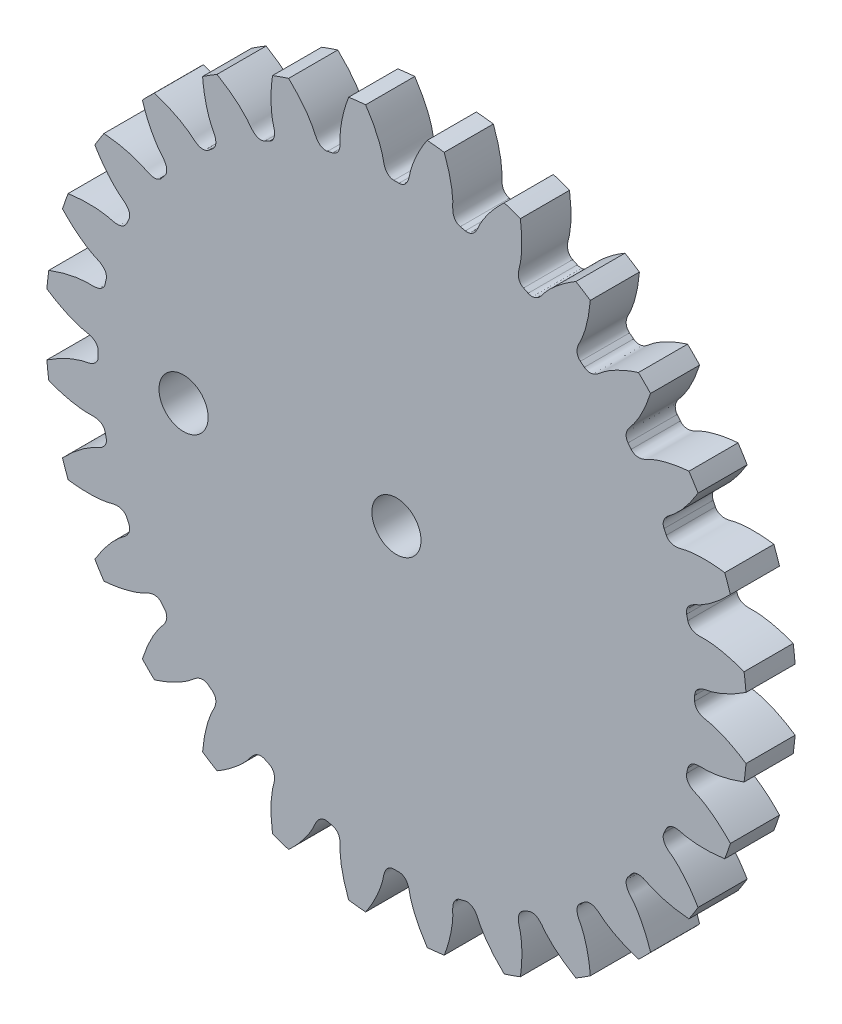
from build123d import *

# Parameters (mm, degrees)
GEAR_BASESKETCH_R                         = 21.428571429
COMPANY_STANDARD_1_40_0000MM_P_D_DEPTH    = 1.5
TOOTH_CUT_D_P_17_7800_P_A_20_000DEG_DEPTH = 2.5
TOOTH_PATTERN_28_28_COUNT                 = 28
SKETCH1_R                                 = 1.5
CUT_EXTRUDE2_DEPTH                        = 4.0000001


with BuildPart() as part:
    # Gear-BaseSketch → Company Standard _1_ 40.0000mm P.D (new body, symmetric)
    with BuildSketch(Plane.XY):
        Circle(GEAR_BASESKETCH_R)
    extrude(amount=COMPANY_STANDARD_1_40_0000MM_P_D_DEPTH, both=True)

    # Tooth-Sketch_ Backlash_ 0.0000mm → Tooth-Cut_ D.P._17.7800_ P.A._20.000deg (cut, symmetric)
    with BuildSketch(Plane.XY):
        with BuildLine():
            ThreePointArc((-1.941515883, 21.437443045), (0, 21.525181724), (1.941515883, 21.437443045))
            add(Edge.make_bspline(
                [(1.941515883, 21.437443045), (1.804383903, 21.236772748), (1.61597143, 20.939630853), (1.396648333, 20.544995883), (1.260965885, 20.277945397), (1.146222447, 20.029683932), (1.050818251, 19.801367101), (0.973092052, 19.594057565), (0.911347249, 19.408719448), (0.86379375, 19.246225427), (0.828741644, 19.107326597), (0.806553264, 19.004305484), (0.793873619, 18.93331407), (0.785294902, 18.886826481), (0.776304045, 18.845094375), (0.760127999, 18.778188715), (0.732872274, 18.687588776), (0.686082538, 18.575119592), (0.622527219, 18.465371892), (0.531261821, 18.357199811), (0.380490672, 18.247605564), (0.240757521, 18.214046733), (0.156605949, 18.213612455)],
                knots=[0, 0, 0, 0, 0.190811628, 0.275995392, 0.354364454, 0.425918816, 0.490658478, 0.548583439, 0.5996937, 0.64398926, 0.681470121, 0.712136282, 0.726696296, 0.738084041, 0.749246412, 0.760204972, 0.792121225, 0.823409511, 0.855638661, 0.891318039, 0.933790828, 1, 1, 1, 1], degree=3))
            ThreePointArc((0.156605949, 18.213612455), (0, 18.214285714), (-0.156605949, 18.213612455))
            add(Edge.make_bspline(
                [(-1.941515883, 21.437443045), (-1.804383903, 21.236772748), (-1.61597143, 20.939630853), (-1.396648333, 20.544995883), (-1.260965885, 20.277945397), (-1.146222447, 20.029683932), (-1.050818251, 19.801367101), (-0.973092052, 19.594057565), (-0.911347249, 19.408719448), (-0.86379375, 19.246225427), (-0.828741644, 19.107326597), (-0.806553264, 19.004305484), (-0.793873619, 18.93331407), (-0.785294902, 18.886826481), (-0.776304045, 18.845094375), (-0.760127999, 18.778188715), (-0.732872274, 18.687588776), (-0.686082538, 18.575119592), (-0.622527219, 18.465371892), (-0.531261821, 18.357199811), (-0.380490672, 18.247605564), (-0.240757521, 18.214046733), (-0.156605949, 18.213612455)],
                knots=[0, 0, 0, 0, 0.190811628, 0.275995392, 0.354364454, 0.425918816, 0.490658478, 0.548583439, 0.5996937, 0.64398926, 0.681470121, 0.712136282, 0.726696296, 0.738084041, 0.749246412, 0.760204972, 0.792121225, 0.823409511, 0.855638661, 0.891318039, 0.933790828, 1, 1, 1, 1], degree=3))
        make_face()
    tooth_cut_d_p_17_7800_p_a_20_000deg = extrude(amount=TOOTH_CUT_D_P_17_7800_P_A_20_000DEG_DEPTH, both=True, mode=Mode.SUBTRACT)

    # Tooth Pattern_ 28 _ 28: Tooth-Cut_ D.P._17.7800_ P.A._20.000deg ×28 about axis
    tooth_pattern_28_28_axis = Axis((0, 0, -88.99), (0, 0, 1))
    for i in range(1, TOOTH_PATTERN_28_28_COUNT):
        add(tooth_cut_d_p_17_7800_p_a_20_000deg.rotate(tooth_pattern_28_28_axis, i * 360 / TOOTH_PATTERN_28_28_COUNT), mode=Mode.SUBTRACT)

    # Sketch1 → Cut-Extrude2 (cut, through all)
    with BuildSketch(Plane.XY.offset(1.5)):
        Circle(SKETCH1_R)
        with Locations((-13, 0)):
            Circle(SKETCH1_R)
    extrude(amount=-CUT_EXTRUDE2_DEPTH, mode=Mode.SUBTRACT)


solid = part.part
